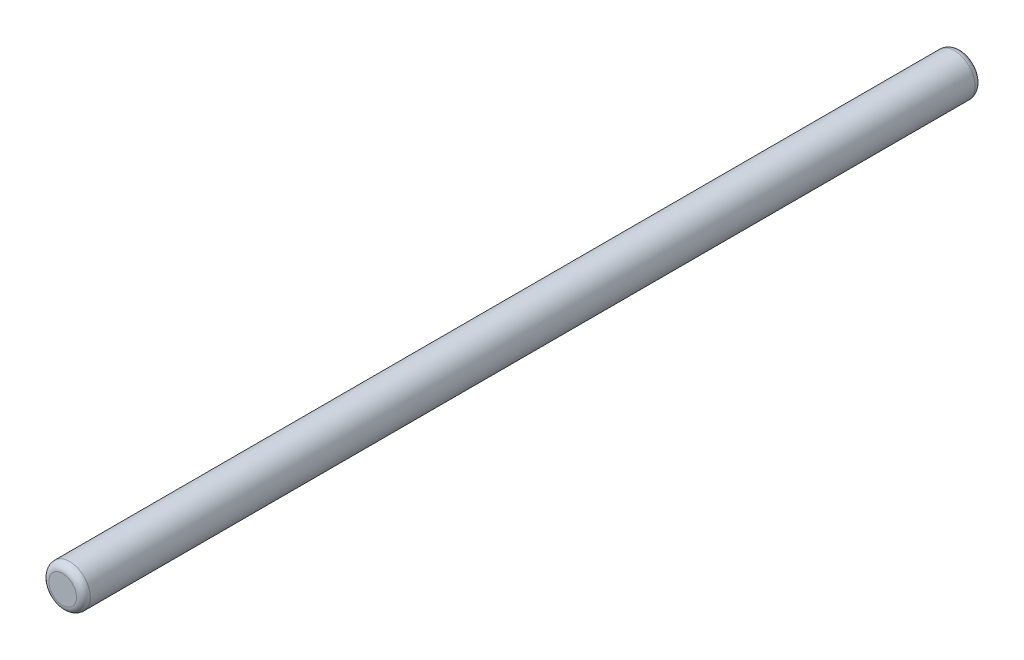
from build123d import *

# Parameters (mm, degrees)
SCHIZZO1_R                   = 1.5
ESTRUSIONE_ESTRUSIONE1_DEPTH = 65
RACCORDO1_R                  = 0.5


with BuildPart() as part:
    # Schizzo1 → Estrusione-Estrusione1 (new body)
    with BuildSketch(Plane.XY):
        Circle(SCHIZZO1_R)
    extrude(amount=ESTRUSIONE_ESTRUSIONE1_DEPTH)

    # Raccordo1
    raccordo1_edges = [part.edges().sort_by_distance(p)[0] for p in [
        (-1.5, 0, 0),
        (-1.5, 0, 65),
    ]]
    fillet(raccordo1_edges, radius=RACCORDO1_R)


solid = part.part
